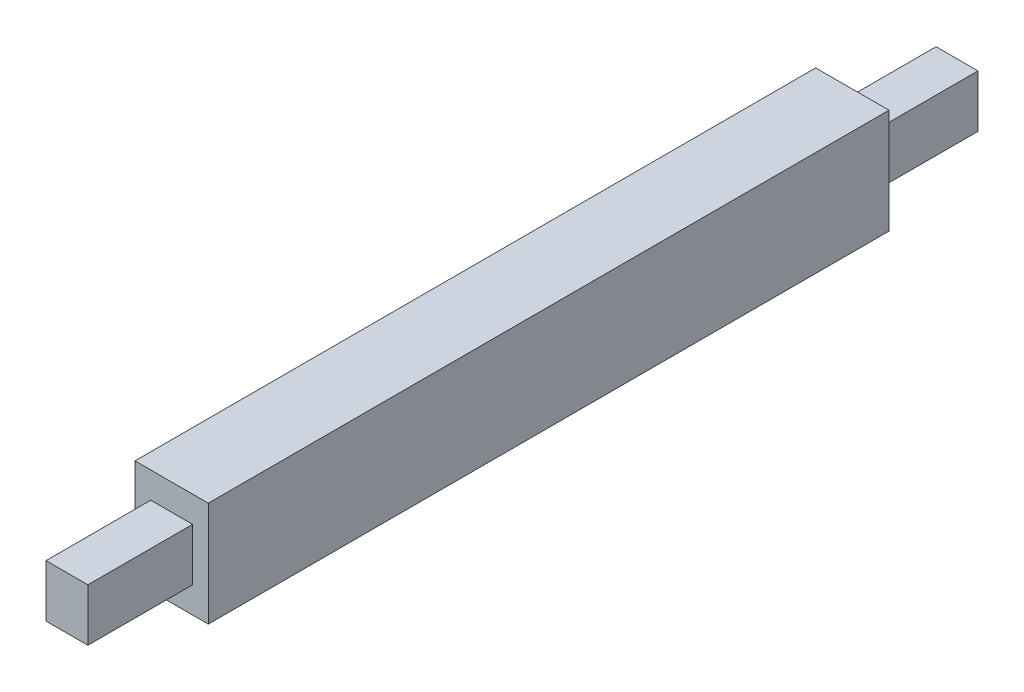
from build123d import *

# Parameters (mm, degrees)
SKETCH1_W           = 7
SKETCH1_H           = 10
BOSS_EXTRUDE1_DEPTH = 32.5
SKETCH2_W           = 4
SKETCH2_H           = 5
BOSS_EXTRUDE2_DEPTH = 10
SKETCH3_W           = 4
SKETCH3_H           = 5
BOSS_EXTRUDE3_DEPTH = 10


with BuildPart() as part:
    # Sketch1 → Boss-Extrude1 (new body, symmetric)
    with BuildSketch(Plane.XY):
        Rectangle(SKETCH1_W, SKETCH1_H)
    extrude(amount=BOSS_EXTRUDE1_DEPTH, both=True)

    # Sketch2 → Boss-Extrude2 (add)
    with BuildSketch(Plane.XY.offset(32.5)):
        Rectangle(SKETCH2_W, SKETCH2_H)
    extrude(amount=BOSS_EXTRUDE2_DEPTH)

    # Sketch3 → Boss-Extrude3 (add)
    with BuildSketch(Plane(origin=(0, 0, -32.5), x_dir=(-1, 0, 0), z_dir=(0, 0, -1))):
        Rectangle(SKETCH3_W, SKETCH3_H)
    extrude(amount=BOSS_EXTRUDE3_DEPTH)


solid = part.part
